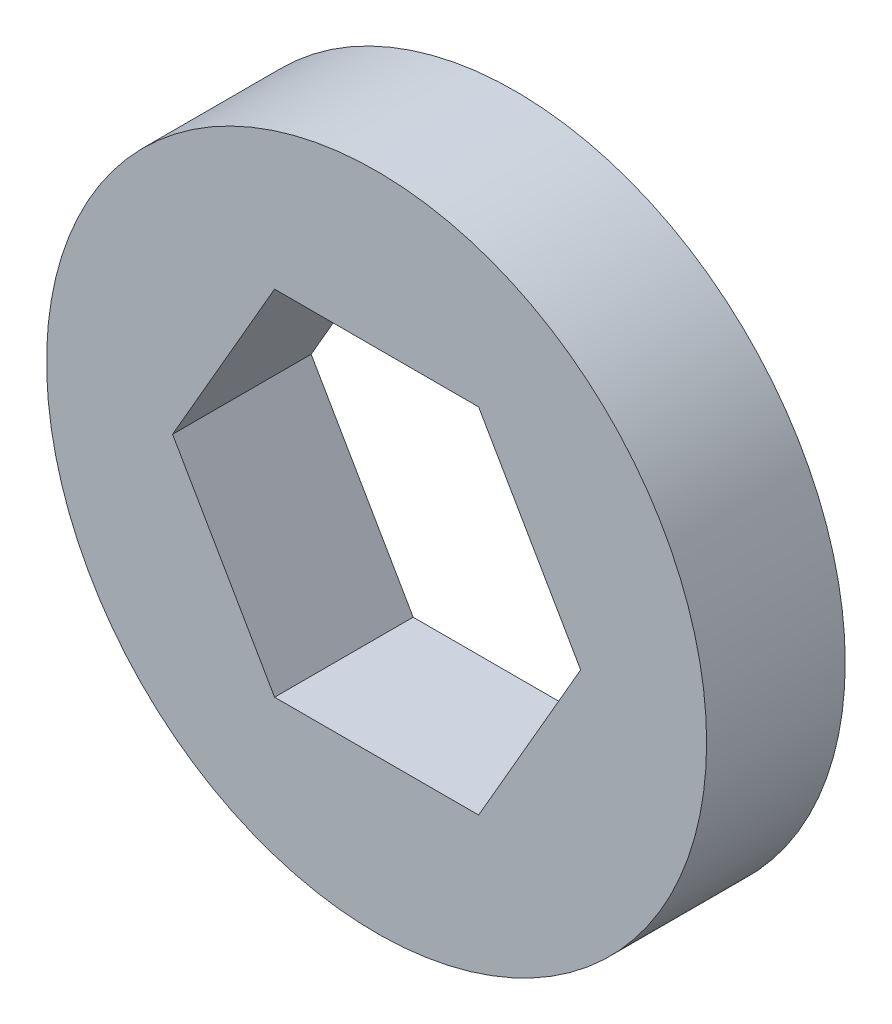
from build123d import *

# Parameters (mm, degrees)
SKETCH1_R           = 4.7625
BOSS_EXTRUDE1_DEPTH = 2


with BuildPart() as part:
    # Sketch1 → Boss-Extrude1 (new body)
    with BuildSketch(Plane.XY):
        Circle(SKETCH1_R)
        Polygon((2.944486373, 0), (1.472243186, 2.55), (-1.472243186, 2.55), (-2.944486373, 0), (-1.472243186, -2.55), (1.472243186, -2.55), align=None, mode=Mode.SUBTRACT)
    extrude(amount=BOSS_EXTRUDE1_DEPTH)


solid = part.part
